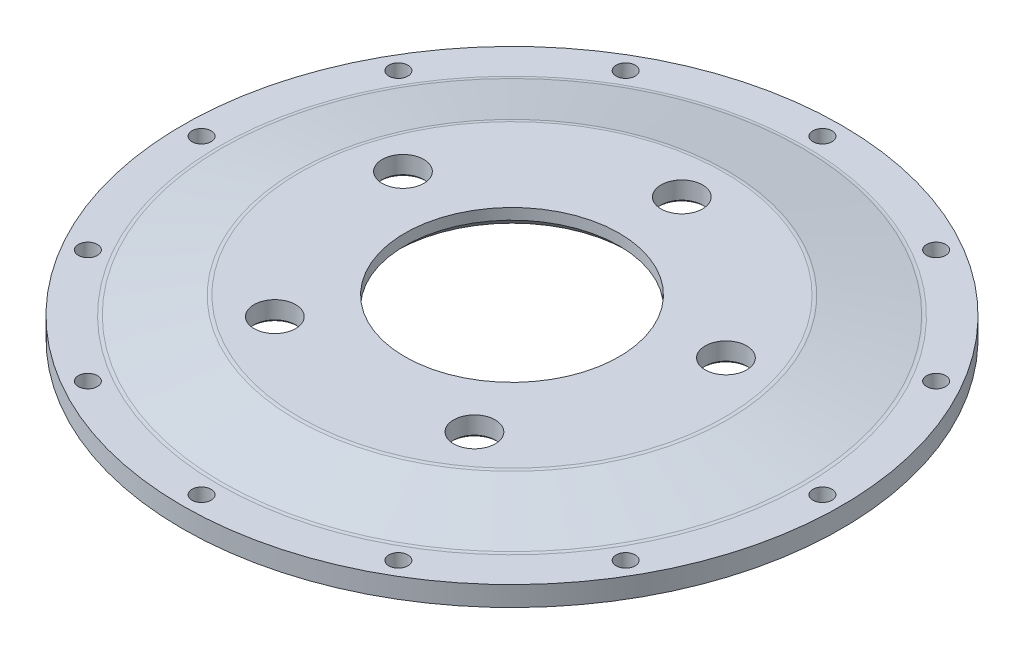
from build123d import *

# Parameters (mm, degrees)
SKETCH1_R           = 110.925
SKETCH1_R_2         = 3.2125
SKETCH1_R_3         = 98.075
BOSS_EXTRUDE1_DEPTH = 6.7
SKETCH2_R           = 72
SKETCH2_R_2         = 36.055
SKETCH2_R_3         = 7
BOSS_EXTRUDE3_DEPTH = 6.7
FILLET1_R           = 5
FILLET2_R           = 5
CHAMFER1_SIZE       = 3
CHAMFER2_SIZE       = 0.8
FILLET7_R           = 2.5
FILLET8_R           = 2.5


with BuildPart() as part:
    # Sketch1 → Boss-Extrude1 (new body)
    with BuildSketch(Plane(origin=(0, 0, 0), x_dir=(1, 0, 0), z_dir=(0, 1, 0))):
        with Locations(Location((0, 0, 0), (0, 0, 270))):
            Circle(SKETCH1_R)
        with Locations(Location((0, 104.5, 0), (0, 0, 270))):
            Circle(SKETCH1_R_2, mode=Mode.SUBTRACT)
        with Locations(Location((0, 0, 0), (0, 0, 270))):
            Circle(SKETCH1_R_3, mode=Mode.SUBTRACT)
        with Locations(Location((52.25, 90.499654695, 0), (0, 0, 270))):
            Circle(SKETCH1_R_2, mode=Mode.SUBTRACT)
        with Locations(Location((90.499654695, 52.25, 0), (0, 0, 270))):
            Circle(SKETCH1_R_2, mode=Mode.SUBTRACT)
        with Locations(Location((104.5, 0, 0), (0, 0, 270))):
            Circle(SKETCH1_R_2, mode=Mode.SUBTRACT)
        with Locations(Location((90.499654695, -52.25, 0), (0, 0, 270))):
            Circle(SKETCH1_R_2, mode=Mode.SUBTRACT)
        with Locations(Location((52.25, -90.499654695, 0), (0, 0, 270))):
            Circle(SKETCH1_R_2, mode=Mode.SUBTRACT)
        with Locations(Location((0, -104.5, 0), (0, 0, 270))):
            Circle(SKETCH1_R_2, mode=Mode.SUBTRACT)
        with Locations(Location((-52.25, -90.499654695, 0), (0, 0, 270))):
            Circle(SKETCH1_R_2, mode=Mode.SUBTRACT)
        with Locations(Location((-90.499654695, -52.25, 0), (0, 0, 270))):
            Circle(SKETCH1_R_2, mode=Mode.SUBTRACT)
        with Locations(Location((-104.5, 0, 0), (0, 0, 270))):
            Circle(SKETCH1_R_2, mode=Mode.SUBTRACT)
        with Locations(Location((-90.499654695, 52.25, 0), (0, 0, 270))):
            Circle(SKETCH1_R_2, mode=Mode.SUBTRACT)
        with Locations(Location((-52.25, 90.499654695, 0), (0, 0, 270))):
            Circle(SKETCH1_R_2, mode=Mode.SUBTRACT)
    extrude(amount=BOSS_EXTRUDE1_DEPTH)



with BuildPart() as body_2:
    # Sketch2 → Boss-Extrude3 (new body)
    with BuildSketch(Plane(origin=(0, 12.7, 0), x_dir=(1, 0, 0), z_dir=(0, 1, 0))):
        with Locations(Location((0, 0, 0), (0, 0, 270))):
            Circle(SKETCH2_R)
        with Locations(Location((0, 0, 0), (0, 0, 270))):
            Circle(SKETCH2_R_2, mode=Mode.SUBTRACT)
        with Locations(Location((0, 57.15, 0), (0, 0, 270))):
            Circle(SKETCH2_R_3, mode=Mode.SUBTRACT)
        with Locations(Location((54.352879906, 17.660321229, 0), (0, 0, 270))):
            Circle(SKETCH2_R_3, mode=Mode.SUBTRACT)
        with Locations(Location((33.591927169, -46.235321229, 0), (0, 0, 270))):
            Circle(SKETCH2_R_3, mode=Mode.SUBTRACT)
        with Locations(Location((-33.591927169, -46.235321229, 0), (0, 0, 270))):
            Circle(SKETCH2_R_3, mode=Mode.SUBTRACT)
        with Locations(Location((-54.352879906, 17.660321229, 0), (0, 0, 270))):
            Circle(SKETCH2_R_3, mode=Mode.SUBTRACT)
    extrude(amount=-BOSS_EXTRUDE3_DEPTH)


with BuildPart() as part_1:
    add(part.part)

    add(body_2.part)  # Sweep3 merges body 2
    # Sweep3: sweep along a curve in space
    with BuildLine() as sweep3_path:
        ThreePointArc((0, 6, 72), (50.911688245, 6, 50.911688245), (72, 6, 0))
        ThreePointArc((72, 6, 0), (50.911688245, 6, -50.911688245), (0, 6, -72))
        ThreePointArc((0, 6, -72), (-50.911688245, 6, -50.911688245), (-72, 6, 0))
        ThreePointArc((-72, 6, 0), (-50.911688245, 6, 50.911688245), (0, 6, 72))
    # Sketch4 → Sweep3 (sweep)
    with BuildSketch(Plane.XY):
        Polygon((72, 12.7), (98.075, 6.7), (98.075, 0), (72, 6), align=None)
    sweep(path=sweep3_path.line)

    # Fillet1
    fillet1_edges = [part_1.edges().sort_by_distance(p)[0] for p in [
        (50.911688245, 12.7, 50.911688245),
    ]]
    fillet(fillet1_edges, radius=FILLET1_R)

    # Fillet2
    fillet2_edges = [part_1.edges().sort_by_distance(p)[0] for p in [
        (69.349497565, 6.7, 69.349497565),
    ]]
    fillet(fillet2_edges, radius=FILLET2_R)

    # Chamfer1
    chamfer1_edges = [part_1.edges().sort_by_distance(p)[0] for p in [
        (0, 6, -36.055),
    ]]
    chamfer(chamfer1_edges, length=CHAMFER1_SIZE)

    # Chamfer2
    chamfer2_edges = [part_1.edges().sort_by_distance(p)[0] for p in [
        (-54.352879906, 6, -24.660321229),
        (-33.591927169, 6, 39.235321229),
        (33.591927169, 6, 39.235321229),
        (54.352879906, 6, -24.660321229),
        (0, 6, -64.15),
    ]]
    chamfer(chamfer2_edges, length=CHAMFER2_SIZE)

    # Fillet7
    fillet7_edges = [part_1.edges().sort_by_distance(p)[0] for p in [
        (50.911688245, 6, -50.911688245),
    ]]
    fillet(fillet7_edges, radius=FILLET7_R)

    # Fillet8
    fillet8_edges = [part_1.edges().sort_by_distance(p)[0] for p in [
        (69.349497565, 0, -69.349497565),
    ]]
    fillet(fillet8_edges, radius=FILLET8_R)


solid = part_1.part
